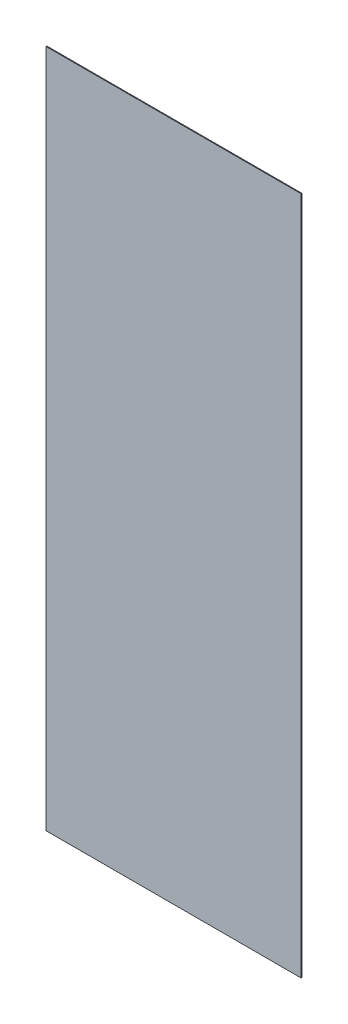
from build123d import *

# Parameters (mm, degrees)
SKETCH_1_W      = 308
SKETCH_1_H      = 820
EXTRUDE_1_DEPTH = 1


with BuildPart() as part:
    # 스케치1 → 보스-돌출1 (new body)
    with BuildSketch(Plane.XY):
        with Locations((154, 410)):
            Rectangle(SKETCH_1_W, SKETCH_1_H)
    extrude(amount=EXTRUDE_1_DEPTH)


solid = part.part
